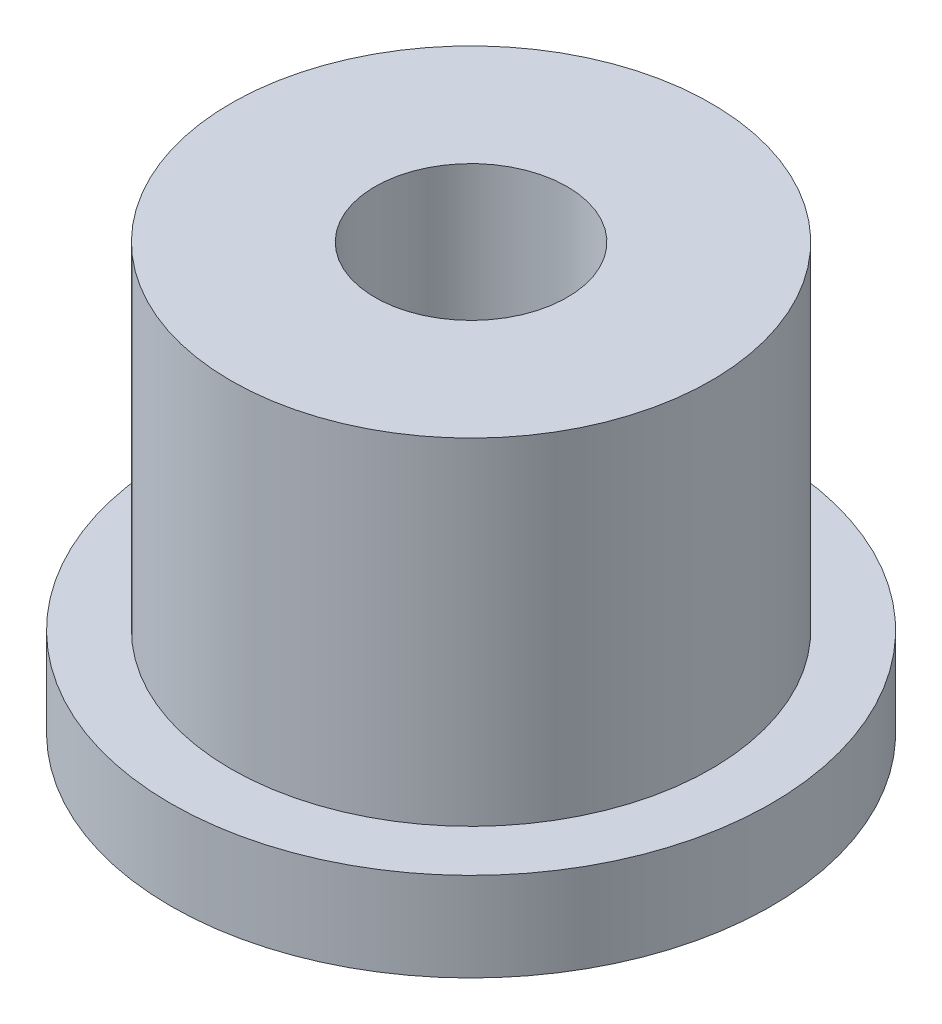
from build123d import *

# Parameters (mm, degrees)
SKETCH1_R           = 5
BOSS_EXTRUDE1_DEPTH = 1.48
SKETCH2_R           = 4
BOSS_EXTRUDE2_DEPTH = 5.6
SKETCH3_R           = 1.6
CUT_EXTRUDE1_DEPTH  = 8.08
SKETCH4_R           = 3
CUT_EXTRUDE2_DEPTH  = 2


with BuildPart() as part:
    # Sketch1 → Boss-Extrude1 (new body)
    with BuildSketch(Plane(origin=(0, 0, 0), x_dir=(1, 0, 0), z_dir=(0, 1, 0))):
        Circle(SKETCH1_R)
    extrude(amount=BOSS_EXTRUDE1_DEPTH)

    # Sketch2 → Boss-Extrude2 (add)
    with BuildSketch(Plane(origin=(0, 1.48, 0), x_dir=(1, 0, 0), z_dir=(0, 1, 0))):
        Circle(SKETCH2_R)
    extrude(amount=BOSS_EXTRUDE2_DEPTH)

    # Sketch3 → Cut-Extrude1 (cut, through all)
    with BuildSketch(Plane.XZ):
        Circle(SKETCH3_R)
    extrude(amount=-CUT_EXTRUDE1_DEPTH, mode=Mode.SUBTRACT)

    # Sketch4 → Cut-Extrude2 (cut)
    with BuildSketch(Plane.XZ):
        Circle(SKETCH4_R)
    extrude(amount=-CUT_EXTRUDE2_DEPTH, mode=Mode.SUBTRACT)


solid = part.part
